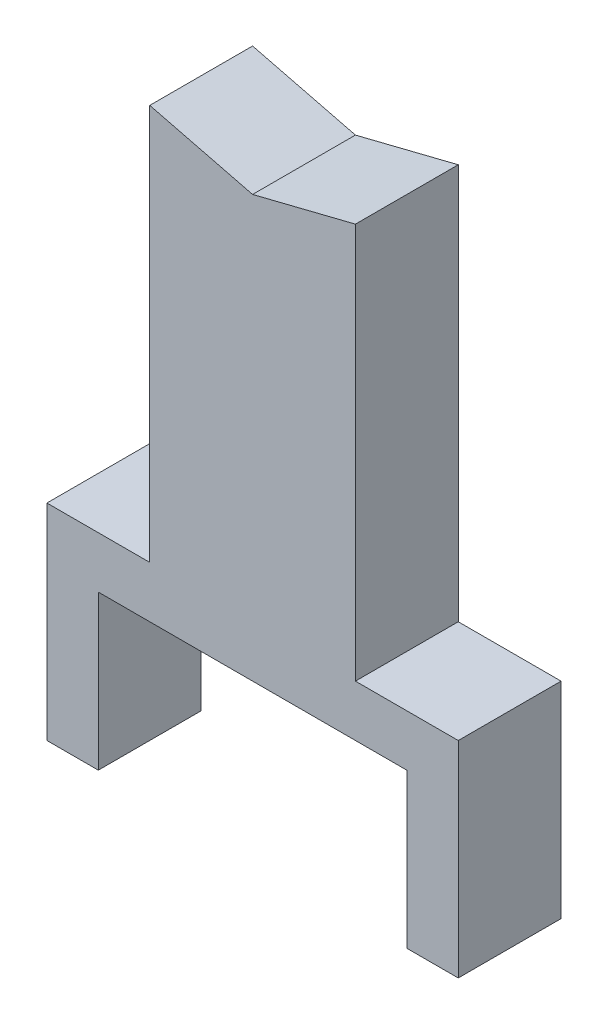
from build123d import *

# Parameters (mm, degrees)
BOSS_EXTRUDE1_DEPTH = 25.4


with BuildPart() as part:
    # Sketch1 → Boss-Extrude1 (new body, symmetric)
    with BuildSketch(Plane.XY):
        Polygon((0, 284.4038), (-50.8, 297.1038), (-50.8, 101.6), (-101.6, 101.6), (-101.6, 0), (-76.2, 0), (-76.2, 76.2), (0, 76.2), (76.2, 76.2), (76.2, 0), (101.6, 0), (101.6, 101.6), (50.8, 101.6), (50.8, 297.1038), align=None)
    extrude(amount=BOSS_EXTRUDE1_DEPTH, both=True)


solid = part.part
